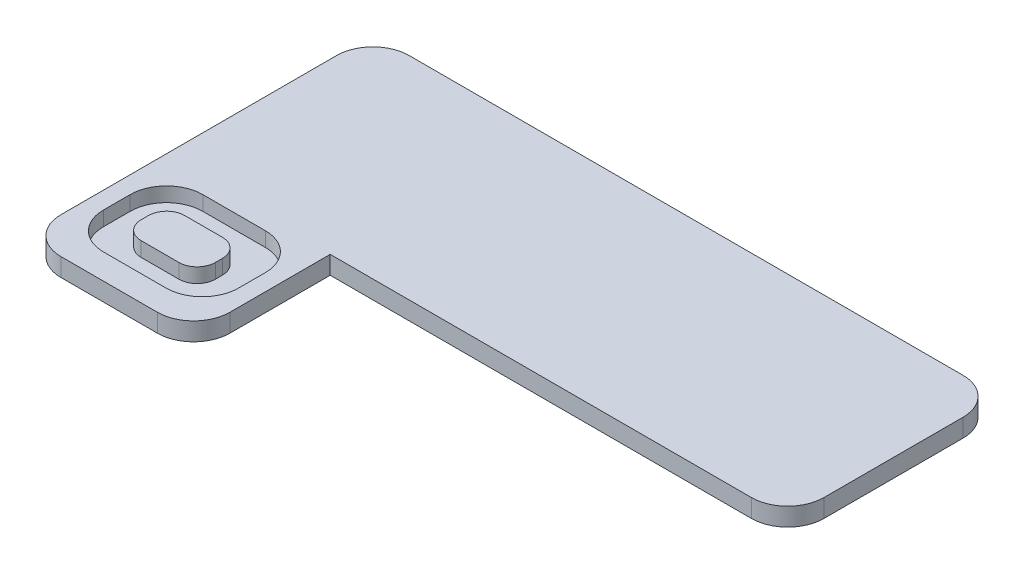
from build123d import *

# Parameters (mm, degrees)
BOSS_EXTRUDE1_DEPTH = 1.27
CUT_EXTRUDE1_DEPTH  = 1.016


with BuildPart() as part:
    # Sketch1 → Boss-Extrude1 (new body)
    with BuildSketch(Plane(origin=(0, 0, 0), x_dir=(1, 0, 0), z_dir=(0, 1, 0))):
        with BuildLine():
            Line((2.54, 0), (41.304776771, 0))
            ThreePointArc((41.304776771, 0), (43.100827995, -0.743948776), (43.844776771, -2.54))
            Line((43.844776771, -2.54), (43.844776771, -12.274039018))
            ThreePointArc((43.844776771, -12.274039018), (43.100827995, -14.070090242), (41.304776771, -14.814039018))
            Line((41.304776771, -14.814039018), (11.827337603, -14.814039018))
            Line((11.827337603, -14.814039018), (11.827337603, -21.831483546))
            ThreePointArc((11.827337603, -21.831483546), (11.083388827, -23.62753477), (9.287337603, -24.371483546))
            Line((9.287337603, -24.371483546), (2.54, -24.371483546))
            ThreePointArc((2.54, -24.371483546), (0.743948776, -23.62753477), (0, -21.831483546))
            Line((0, -21.831483546), (0, -14.814039018))
            Line((0, -14.814039018), (0, -2.54))
            ThreePointArc((0, -2.54), (0.743948776, -0.743948776), (2.54, 0))
        make_face()
    extrude(amount=BOSS_EXTRUDE1_DEPTH)

    # Sketch2 → Cut-Extrude1 (cut)
    with BuildSketch(Plane(origin=(0, 1.27, 0), x_dir=(1, 0, 0), z_dir=(0, 1, 0))):
        with BuildLine():
            Line((8.125200896, -15.6495751), (3.744615047, -15.6495751))
            ThreePointArc((3.744615047, -15.6495751), (1.948563823, -16.393523876), (1.204615047, -18.1895751))
            Line((1.204615047, -18.1895751), (1.204615047, -20.061482924))
            ThreePointArc((1.204615047, -20.061482924), (1.948563823, -21.857534148), (3.744615047, -22.601482924))
            Line((3.744615047, -22.601482924), (8.125200896, -22.601482924))
            ThreePointArc((8.125200896, -22.601482924), (9.921252121, -21.857534148), (10.665200896, -20.061482924))
            Line((10.665200896, -20.061482924), (10.665200896, -18.1895751))
            ThreePointArc((10.665200896, -18.1895751), (9.921252121, -16.393523876), (8.125200896, -15.6495751))
        make_face()
        with BuildLine():
            Line((4.384925651, -17.552804899), (7.030054434, -17.552804899))
            ThreePointArc((7.030054434, -17.552804899), (7.928080046, -17.924779287), (8.300054434, -18.822804899))
            Line((8.300054434, -18.822804899), (8.300054434, -19.330205148))
            ThreePointArc((8.300054434, -19.330205148), (7.928080046, -20.228230761), (7.030054434, -20.600205148))
            Line((7.030054434, -20.600205148), (4.384925651, -20.600205148))
            ThreePointArc((4.384925651, -20.600205148), (3.486900039, -20.228230761), (3.114925651, -19.330205148))
            Line((3.114925651, -19.330205148), (3.114925651, -18.822804899))
            ThreePointArc((3.114925651, -18.822804899), (3.486900039, -17.924779287), (4.384925651, -17.552804899))
        make_face(mode=Mode.SUBTRACT)
    extrude(amount=-CUT_EXTRUDE1_DEPTH, mode=Mode.SUBTRACT)


solid = part.part
